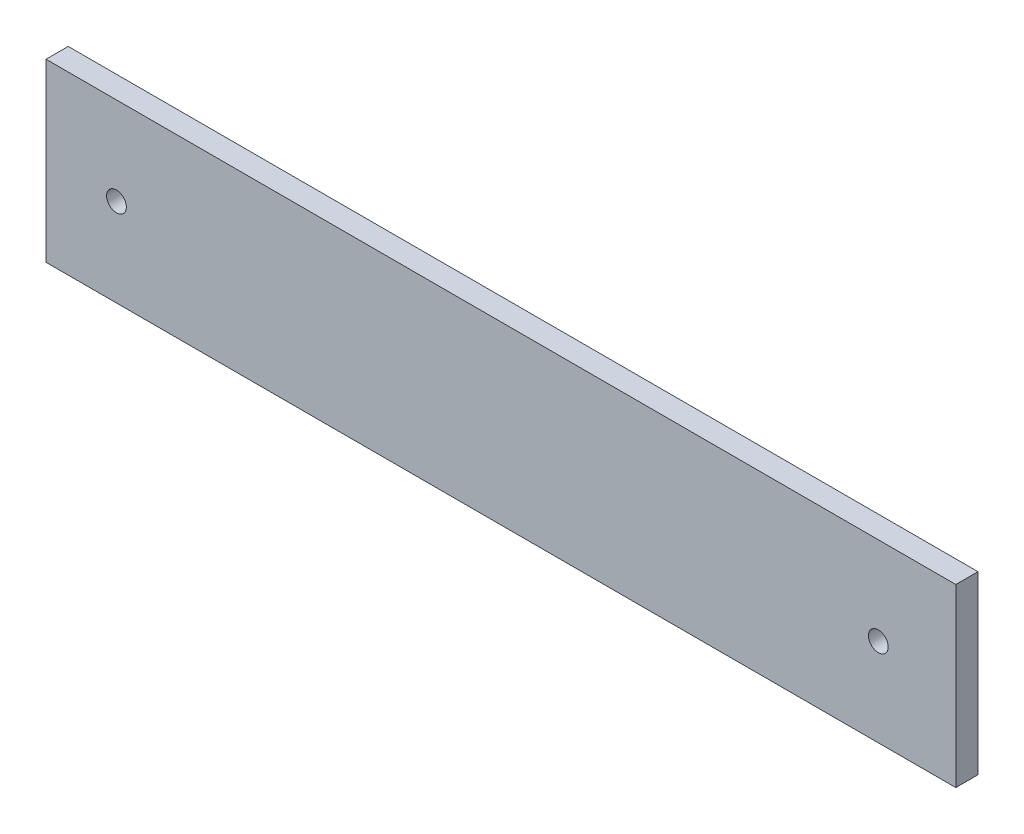
from build123d import *

# Parameters (mm, degrees)
SKETCH1_W           = 130.17064968
SKETCH1_H           = 25.16502177
SKETCH1_R           = 1.415
BOSS_EXTRUDE1_DEPTH = 3.175


with BuildPart() as part:
    # Sketch1 → Boss-Extrude1 (new body)
    with BuildSketch(Plane.XY):
        with Locations((5.626542839, 1.871415634)):
            Rectangle(SKETCH1_W, SKETCH1_H)
        with Locations((-49.374953397, 1.874992989)):
            Circle(SKETCH1_R, mode=Mode.SUBTRACT)
        with Locations((59.625046603, 1.874992989)):
            Circle(SKETCH1_R, mode=Mode.SUBTRACT)
    extrude(amount=BOSS_EXTRUDE1_DEPTH)


solid = part.part
